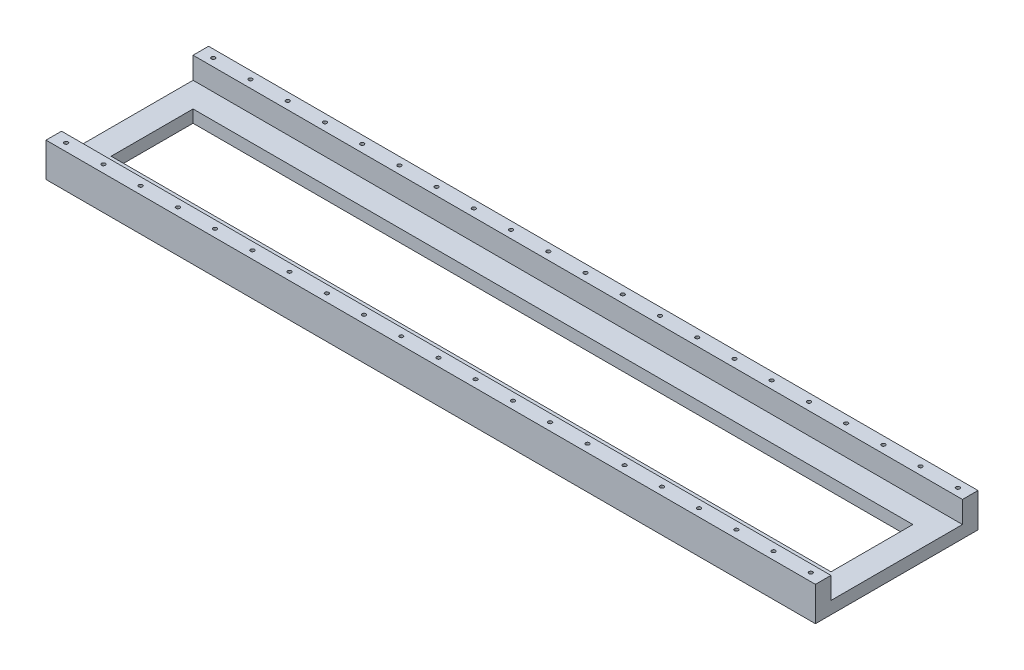
from build123d import *

# Parameters (mm, degrees)
SKETCH1_W           = 1240
SKETCH1_H           = 262
BOSS_EXTRUDE1_DEPTH = 20
SKETCH2_W           = 1240
SKETCH2_H           = 25
BOSS_EXTRUDE2_DEPTH = 35
SKETCH3_R           = 3
CUT_EXTRUDE1_DEPTH  = 10
SKETCH4_R           = 3
CUT_EXTRUDE2_DEPTH  = 10
SKETCH5_W           = 1160
SKETCH5_H           = 132
CUT_EXTRUDE3_DEPTH  = 21


with BuildPart() as part:
    # Sketch1 → Boss-Extrude1 (new body)
    with BuildSketch(Plane(origin=(0, 0, 0), x_dir=(1, 0, 0), z_dir=(0, 1, 0))):
        with Locations((620, 131)):
            Rectangle(SKETCH1_W, SKETCH1_H)
    extrude(amount=BOSS_EXTRUDE1_DEPTH)

    # Sketch2 → Boss-Extrude2 (add)
    with BuildSketch(Plane(origin=(0, 20, 0), x_dir=(1, 0, 0), z_dir=(0, 1, 0))):
        with Locations((620, 12.5)):
            Rectangle(SKETCH2_W, SKETCH2_H)
        with Locations((620, 249.5)):
            Rectangle(SKETCH2_W, SKETCH2_H)
    extrude(amount=BOSS_EXTRUDE2_DEPTH)

    # Sketch3 → Cut-Extrude1 (cut)
    with BuildSketch(Plane(origin=(0, 55, 0), x_dir=(1, 0, 0), z_dir=(0, 1, 0))):
        with Locations((20, 12.5)):
            Circle(SKETCH3_R)
        with Locations((80, 12.5)):
            Circle(SKETCH3_R)
        with Locations((140, 12.5)):
            Circle(SKETCH3_R)
        with Locations((200, 12.5)):
            Circle(SKETCH3_R)
        with Locations((260, 12.5)):
            Circle(SKETCH3_R)
        with Locations((320, 12.5)):
            Circle(SKETCH3_R)
        with Locations((380, 12.5)):
            Circle(SKETCH3_R)
        with Locations((440, 12.5)):
            Circle(SKETCH3_R)
        with Locations((500, 12.5)):
            Circle(SKETCH3_R)
        with Locations((560, 12.5)):
            Circle(SKETCH3_R)
        with Locations((620, 12.5)):
            Circle(SKETCH3_R)
        with Locations((680, 12.5)):
            Circle(SKETCH3_R)
        with Locations((740, 12.5)):
            Circle(SKETCH3_R)
        with Locations((800, 12.5)):
            Circle(SKETCH3_R)
        with Locations((860, 12.5)):
            Circle(SKETCH3_R)
        with Locations((920, 12.5)):
            Circle(SKETCH3_R)
        with Locations((980, 12.5)):
            Circle(SKETCH3_R)
        with Locations((1040, 12.5)):
            Circle(SKETCH3_R)
        with Locations((1100, 12.5)):
            Circle(SKETCH3_R)
        with Locations((1160, 12.5)):
            Circle(SKETCH3_R)
        with Locations((1220, 12.5)):
            Circle(SKETCH3_R)
    extrude(amount=-CUT_EXTRUDE1_DEPTH, mode=Mode.SUBTRACT)

    # Sketch4 → Cut-Extrude2 (cut)
    with BuildSketch(Plane(origin=(0, 55, 0), x_dir=(1, 0, 0), z_dir=(0, 1, 0))):
        with Locations((20, 249.5)):
            Circle(SKETCH4_R)
        with Locations((80, 249.5)):
            Circle(SKETCH4_R)
        with Locations((140, 249.5)):
            Circle(SKETCH4_R)
        with Locations((200, 249.5)):
            Circle(SKETCH4_R)
        with Locations((260, 249.5)):
            Circle(SKETCH4_R)
        with Locations((320, 249.5)):
            Circle(SKETCH4_R)
        with Locations((380, 249.5)):
            Circle(SKETCH4_R)
        with Locations((440, 249.5)):
            Circle(SKETCH4_R)
        with Locations((500, 249.5)):
            Circle(SKETCH4_R)
        with Locations((560, 249.5)):
            Circle(SKETCH4_R)
        with Locations((620, 249.5)):
            Circle(SKETCH4_R)
        with Locations((680, 249.5)):
            Circle(SKETCH4_R)
        with Locations((740, 249.5)):
            Circle(SKETCH4_R)
        with Locations((800, 249.5)):
            Circle(SKETCH4_R)
        with Locations((860, 249.5)):
            Circle(SKETCH4_R)
        with Locations((920, 249.5)):
            Circle(SKETCH4_R)
        with Locations((980, 249.5)):
            Circle(SKETCH4_R)
        with Locations((1040, 249.5)):
            Circle(SKETCH4_R)
        with Locations((1100, 249.5)):
            Circle(SKETCH4_R)
        with Locations((1160, 249.5)):
            Circle(SKETCH4_R)
        with Locations((1220, 249.5)):
            Circle(SKETCH4_R)
    extrude(amount=-CUT_EXTRUDE2_DEPTH, mode=Mode.SUBTRACT)

    # Sketch5 → Cut-Extrude3 (cut, through all)
    with BuildSketch(Plane(origin=(0, 20, 0), x_dir=(1, 0, 0), z_dir=(0, 1, 0))):
        with Locations((620, 131)):
            Rectangle(SKETCH5_W, SKETCH5_H)
    extrude(amount=-CUT_EXTRUDE3_DEPTH, mode=Mode.SUBTRACT)


solid = part.part
